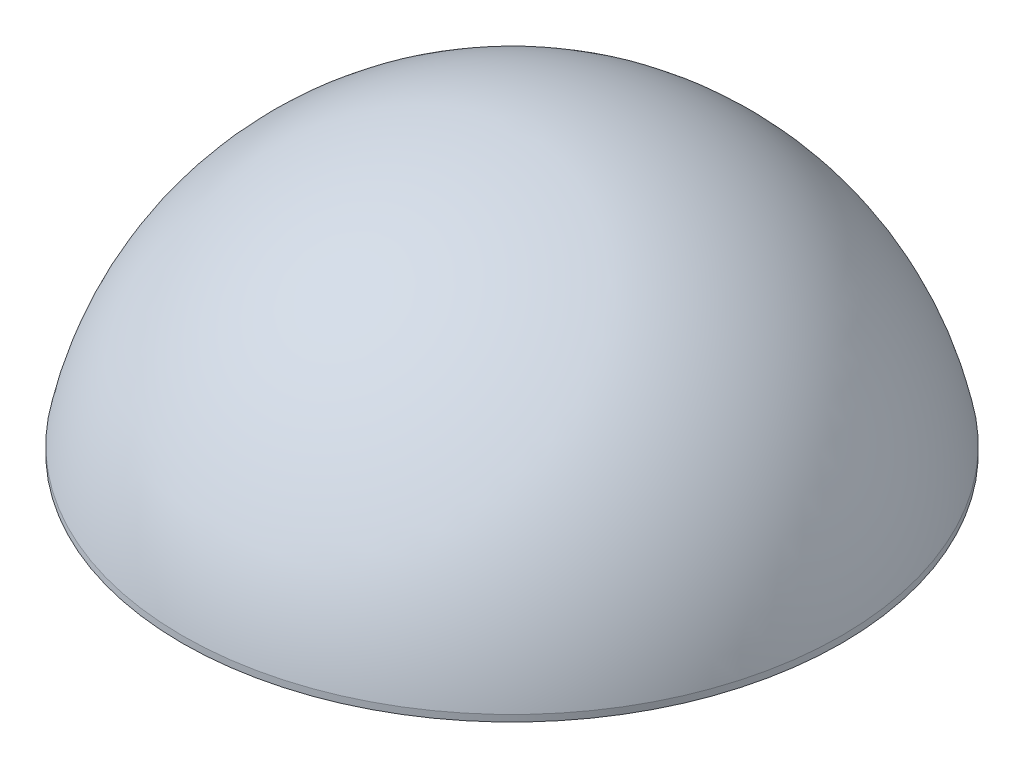
from build123d import *

# Parameters (mm, degrees)
SKETCH1_R         = 127.007592972
EXTRUDE1_DEPTH    = 2.54
DOME1_FACE_RADIUS = 127.007592972
DOME1_HEIGHT      = 104.14


with BuildPart() as part:
    # Sketch1 → Extrude1 (new body)
    with BuildSketch(Plane(origin=(0, 0, 0), x_dir=(1, 0, 0), z_dir=(0, 1, 0))):
        with Locations(Location((0, 0, 0), (0, 0, 270))):  # turned: the seam where the file's is
            Circle(SKETCH1_R)
    extrude(amount=EXTRUDE1_DEPTH)

    # Dome1: a dome of height H over a round flat face of radius A is a cap of a sphere of radius (A * A + H * H) / (2 * H)
    dome1_r = (DOME1_FACE_RADIUS * DOME1_FACE_RADIUS + DOME1_HEIGHT * DOME1_HEIGHT) / (2 * DOME1_HEIGHT)
    dome1_base = Plane((0, 2.54, 0), z_dir=(0, 1, 0))
    with Locations(dome1_base.offset(DOME1_HEIGHT - dome1_r)):
        dome1_ball = Sphere(dome1_r, mode=Mode.PRIVATE)
    add(split(dome1_ball, bisect_by=dome1_base, keep=Keep.TOP, mode=Mode.PRIVATE))


solid = part.part
